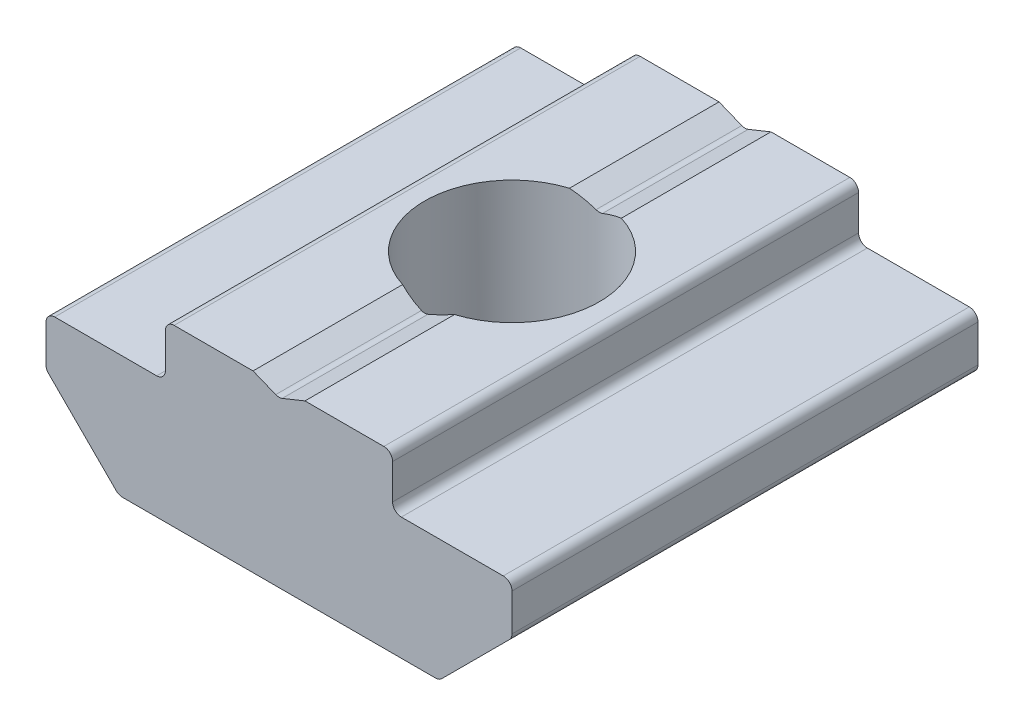
from build123d import *

# Parameters (mm, degrees)
BOSS_EXTRUDE1_DEPTH      = 8
BOSS_EXTRUDE1_DEPTH_BACK = 8
SKETCH9_R                = 3
CUT_EXTRUDE2_DEPTH       = 7
FILLET1_R                = 0.3


with BuildPart() as part:
    # Sketch4 → Boss-Extrude1 (new body, two sides)
    with BuildSketch(Plane.XY) as boss_extrude1_sk:
        Polygon((-8, 4.2), (-8, 2.5), (-5.5, 0), (5.5, 0), (8, 2.5), (8, 4.2), (3.9, 4.2), (3.9, 6), (0.891031267, 6), (0, 5.64), (-0.891031267, 6), (-3.9, 6), (-3.9, 4.2), align=None)
    extrude(amount=BOSS_EXTRUDE1_DEPTH)
    extrude(boss_extrude1_sk.sketch, amount=-BOSS_EXTRUDE1_DEPTH_BACK)

    # Sketch9 → Cut-Extrude2 (cut, through all)
    with BuildSketch(Plane(origin=(0, 0, 0), x_dir=(1, 0, 0), z_dir=(0, 1, 0))):
        Circle(SKETCH9_R)
    extrude(amount=CUT_EXTRUDE2_DEPTH, mode=Mode.SUBTRACT)

    # Fillet1
    fillet1_edges = [part.edges().sort_by_distance(p)[0] for p in [
        (-3.9, 6, 0),
        (-3.9, 4.2, 0),
        (-8, 4.2, 0),
        (-8, 2.5, 0),
        (-5.5, 0, 0),
        (5.5, 0, 0),
        (8, 2.5, 0),
        (8, 4.2, 0),
        (3.9, 4.2, 0),
        (3.9, 6, 0),
        (0, 5.64, -5.5),
        (0, 5.64, 5.5),
    ]]
    fillet(fillet1_edges, radius=FILLET1_R)


solid = part.part
